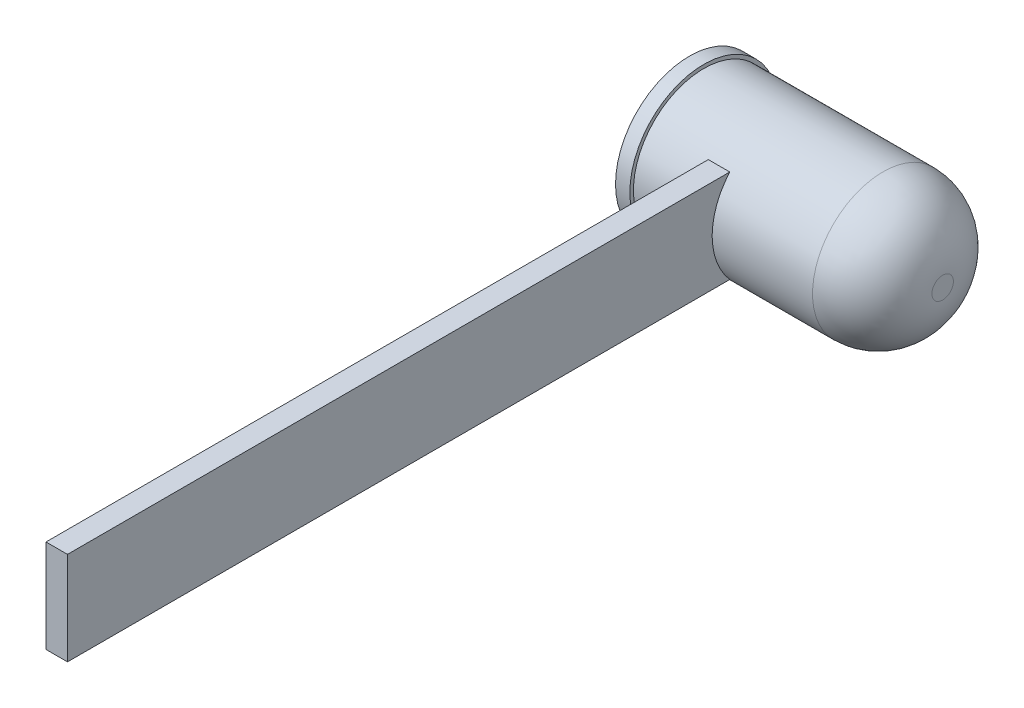
from build123d import *

# Parameters (mm, degrees)
CROQUIS1_R              = 2.95
SALIENTE_EXTRUIR1_DEPTH = 10
REDONDEO1_R             = 2.5
CROQUIS2_R              = 3.1
SALIENTE_EXTRUIR2_DEPTH = 0.6
CROQUIS5_W              = 0.9
CROQUIS5_H              = 3.9
SALIENTE_EXTRUIR4_DEPTH = 27
CROQUIS8_W              = 0.9
CROQUIS8_H              = 3.9
SALIENTE_EXTRUIR5_DEPTH = 2


with BuildPart() as part:
    # Croquis1 → Saliente-Extruir1 (new body)
    with BuildSketch(Plane(origin=(0, 0, 0), x_dir=(0, 0, -1), z_dir=(1, 0, 0))):
        Circle(CROQUIS1_R)
    extrude(amount=SALIENTE_EXTRUIR1_DEPTH)

    # Redondeo1
    redondeo1_edges = [part.edges().sort_by_distance(p)[0] for p in [
        (10, 0, 2.95),
    ]]
    fillet(redondeo1_edges, radius=REDONDEO1_R)

    # Croquis2 → Saliente-Extruir2 (add)
    with BuildSketch(Plane.ZY):
        Circle(CROQUIS2_R)
    extrude(amount=SALIENTE_EXTRUIR2_DEPTH)

    # Croquis5 → Saliente-Extruir4 (add)
    with BuildSketch(Plane.XY.offset(2.949336532)):
        with Locations((2.848707903, 0)):
            Rectangle(CROQUIS5_W, CROQUIS5_H)
    extrude(amount=SALIENTE_EXTRUIR4_DEPTH)

    # Croquis8 → Saliente-Extruir5 (add)
    with BuildSketch(Plane(origin=(0, 0, 2.949336532), x_dir=(-1, 0, 0), z_dir=(0, 0, -1))):
        with Locations((-2.848707903, 0)):
            Rectangle(CROQUIS8_W, CROQUIS8_H)
    extrude(amount=SALIENTE_EXTRUIR5_DEPTH)


solid = part.part
